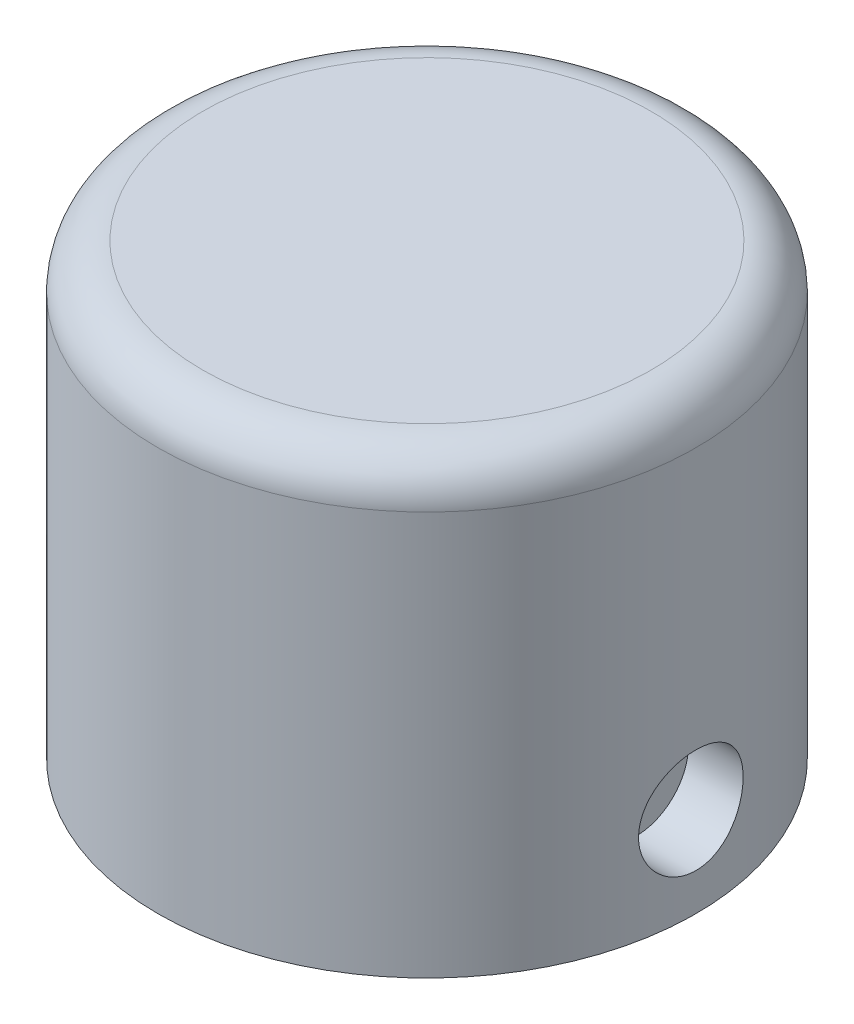
from build123d import *

# Parameters (mm, degrees)
SKETCH1_R               = 18
BOSS_EXTRUDE1_DEPTH     = 30
FILLET1_R               = 3
SKETCH2_W               = 10
SKETCH2_H               = 10
CUT_EXTRUDE1_DEPTH      = 25
SKETCH3_R               = 1.6
CUT_EXTRUDE2_DEPTH      = 24
CUT_EXTRUDE2_DEPTH_BACK = 14.0000001
CUT_EXTRUDE3_START      = -9
SKETCH4_R               = 3.5
CUT_EXTRUDE3_DEPTH      = 20
CUT_EXTRUDE4_START      = -8
CUT_EXTRUDE4_DEPTH      = 16


with BuildPart() as part:
    # Sketch1 → Boss-Extrude1 (new body)
    with BuildSketch(Plane(origin=(0, 0, 0), x_dir=(1, 0, 0), z_dir=(0, 1, 0))):
        Circle(SKETCH1_R)
    extrude(amount=BOSS_EXTRUDE1_DEPTH)

    # Fillet1
    fillet1_edges = [part.edges().sort_by_distance(p)[0] for p in [
        (-18, 30, 0),
    ]]
    fillet(fillet1_edges, radius=FILLET1_R)

    # Sketch2 → Cut-Extrude1 (cut)
    with BuildSketch(Plane.XZ):
        Rectangle(SKETCH2_W, SKETCH2_H)
    extrude(amount=-CUT_EXTRUDE1_DEPTH, mode=Mode.SUBTRACT)

    # Sketch3 → Cut-Extrude2 (cut, two sides)
    with BuildSketch(Plane.ZY.offset(-5)) as cut_extrude2_sk:
        with Locations((0, 6)):
            Circle(SKETCH3_R)
    extrude(amount=CUT_EXTRUDE2_DEPTH, mode=Mode.SUBTRACT)
    extrude(cut_extrude2_sk.sketch, amount=-CUT_EXTRUDE2_DEPTH_BACK, mode=Mode.SUBTRACT)

    # Sketch4 → Cut-Extrude3 (cut)
    with BuildSketch(Plane.ZY.offset(-5).offset(CUT_EXTRUDE3_START)):
        with Locations((0, 6)):
            Circle(SKETCH4_R)
    extrude(amount=-CUT_EXTRUDE3_DEPTH, mode=Mode.SUBTRACT)

    # Sketch5 → Cut-Extrude4 (cut)
    with BuildSketch(Plane(origin=(-5, 0, 0), x_dir=(0, 0, -1), z_dir=(1, 0, 0)).offset(CUT_EXTRUDE4_START)):
        Polygon((-2.814582562, 7.625), (-2.814582562, 4.375), (0, 2.75), (2.814582562, 4.375), (2.814582562, 7.625), (0, 9.25), align=None)
    extrude(amount=-CUT_EXTRUDE4_DEPTH, mode=Mode.SUBTRACT)


solid = part.part
